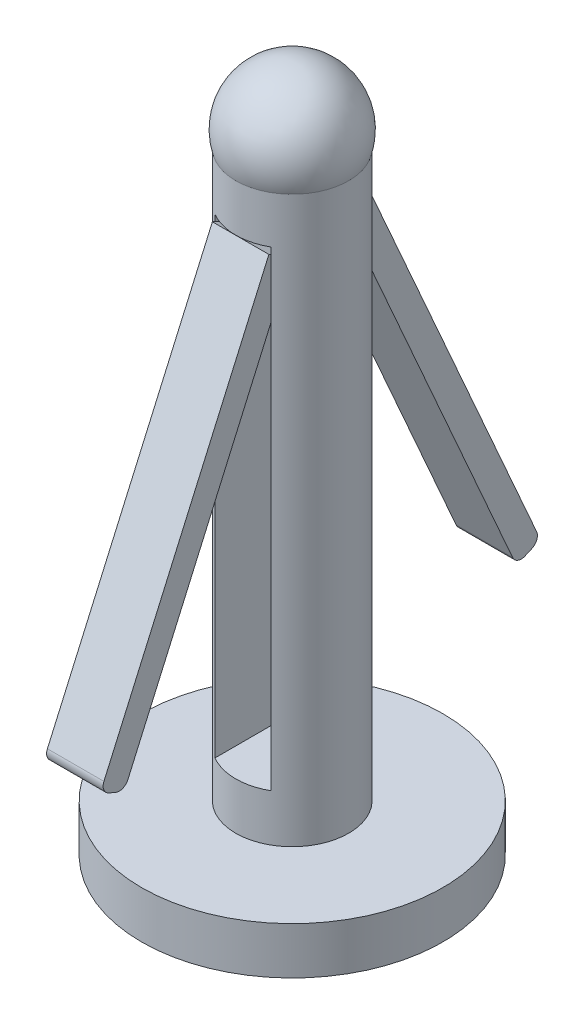
from build123d import *

# Parameters (mm, degrees)
SKETCH1_R               = 16
BOSS_EXTRUDE1_DEPTH     = 5
SKETCH2_R               = 6
BOSS_EXTRUDE2_DEPTH     = 60
DOME1_FACE_RADIUS       = 6
DOME1_HEIGHT            = 8
SKETCH3_W               = 6
SKETCH3_H               = 50
CUT_EXTRUDE1_DEPTH      = 6
CUT_EXTRUDE1_DEPTH_BACK = 6
BOSS_EXTRUDE6_DEPTH     = 6
FILLET2_R               = 1
FILLET4_R               = 1
FILLET2_OF_MIRROR2_R    = 1
FILLET4_OF_MIRROR2_R    = 1


with BuildPart() as part:
    # Sketch1 → Boss-Extrude1 (new body)
    with BuildSketch(Plane(origin=(0, 0, 0), x_dir=(1, 0, 0), z_dir=(0, 1, 0))):
        Circle(SKETCH1_R)
    extrude(amount=-BOSS_EXTRUDE1_DEPTH)

    # Sketch2 → Boss-Extrude2 (add)
    with BuildSketch(Plane(origin=(0, 0, 0), x_dir=(1, 0, 0), z_dir=(0, 1, 0))):
        Circle(SKETCH2_R)
    extrude(amount=BOSS_EXTRUDE2_DEPTH)

    # Dome1: a dome of height H over a round flat face of radius A is a cap of a sphere of radius (A * A + H * H) / (2 * H)
    dome1_r = (DOME1_FACE_RADIUS * DOME1_FACE_RADIUS + DOME1_HEIGHT * DOME1_HEIGHT) / (2 * DOME1_HEIGHT)
    dome1_base = Plane((0, 60, 0), z_dir=(0, 1, 0))
    with Locations(dome1_base.offset(DOME1_HEIGHT - dome1_r)):
        dome1_ball = Sphere(dome1_r, mode=Mode.PRIVATE)
    add(split(dome1_ball, bisect_by=dome1_base, keep=Keep.TOP, mode=Mode.PRIVATE))

    # Sketch3 → Cut-Extrude1 (cut, two sides)
    with BuildSketch(Plane.XY) as cut_extrude1_sk:
        with Locations((-0.023759129, 30)):
            Rectangle(SKETCH3_W, SKETCH3_H)
    extrude(amount=CUT_EXTRUDE1_DEPTH, mode=Mode.SUBTRACT)
    extrude(cut_extrude1_sk.sketch, amount=-CUT_EXTRUDE1_DEPTH_BACK, mode=Mode.SUBTRACT)

    # Sketch4 → Boss-Extrude6 (add)
    with BuildSketch(Plane.ZY.offset(-2.976240871)):
        Polygon((5.454631491, 54.445098747), (23.375133838, 13.829372646), (20.834979102, 12.708603592), (2.914476754, 53.324329693), align=None)
    boss_extrude6 = extrude(amount=BOSS_EXTRUDE6_DEPTH)

    # Fillet2
    fillet2_edges = [part.edges().sort_by_distance(p)[0] for p in [
        (-0.023759129, 13.829372646, 23.375133838),
    ]]
    fillet(fillet2_edges, radius=FILLET2_R)

    # Fillet4
    fillet4_edges = [part.edges().sort_by_distance(p)[0] for p in [
        (-0.023759129, 12.708603592, 20.834979102),
    ]]
    fillet(fillet4_edges, radius=FILLET4_R)

    # Mirror2: Boss-Extrude6 across plane
    add(boss_extrude6.mirror(Plane.XY))

    # Fillet2 of Mirror2
    fillet2_of_mirror2_edges = [part.edges().sort_by_distance(p)[0] for p in [
        (-0.023759129, 13.829372646, -23.375133838),
    ]]
    fillet(fillet2_of_mirror2_edges, radius=FILLET2_OF_MIRROR2_R)

    # Fillet4 of Mirror2
    fillet4_of_mirror2_edges = [part.edges().sort_by_distance(p)[0] for p in [
        (-0.023759129, 12.708603592, -20.834979102),
    ]]
    fillet(fillet4_of_mirror2_edges, radius=FILLET4_OF_MIRROR2_R)


solid = part.part
